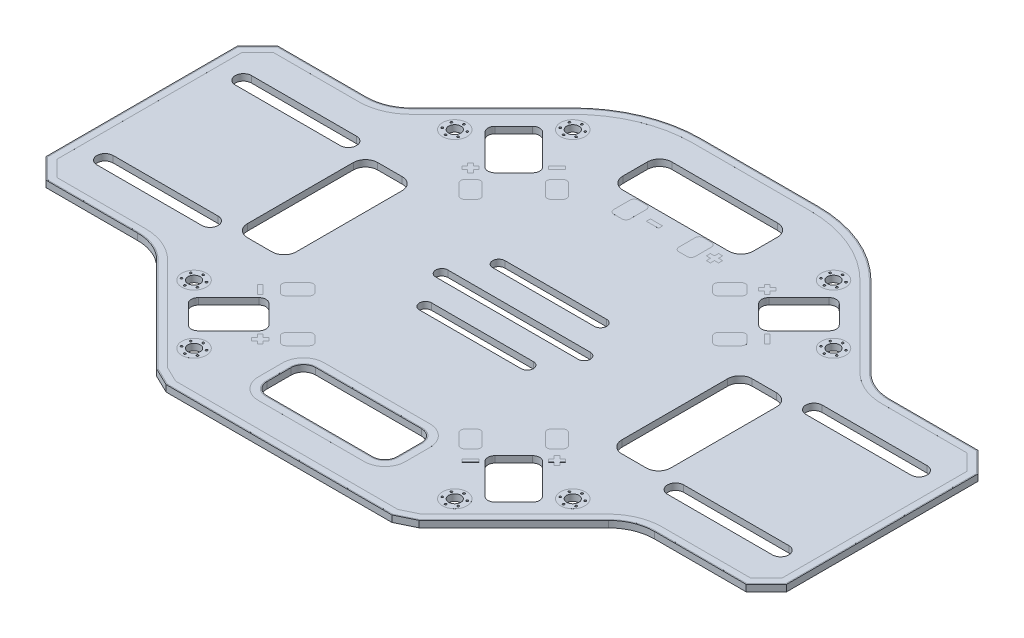
from build123d import *

# Parameters (mm, degrees)
SKETCH1_R                = 1.5
BOSS_EXTRUDE1_DEPTH      = 0.8
BOSS_EXTRUDE1_DEPTH_BACK = 0.8
SKETCH2_R                = 3
SKETCH2_R_2              = 0.25
SKETCH2_R_3              = 1.5
BOSS_EXTRUDE2_DEPTH      = 0.001
BOSS_EXTRUDE4_DEPTH      = 0.001
SKETCH6_R                = 0.25
CUT_EXTRUDE2_DEPTH       = 1.6
SKETCH7_W                = 3
SKETCH7_H                = 1
BOSS_EXTRUDE5_DEPTH      = 0.001


with BuildPart() as part:
    # Sketch1 → Boss-Extrude1 (new body, two sides)
    with BuildSketch(Plane(origin=(0, 0, 0), x_dir=(1, 0, 0), z_dir=(0, 1, 0))) as boss_extrude1_sk:
        with BuildLine():
            Line((-27.75, -57.681401017), (27.75, -57.681401017))
            Line((27.75, -57.681401017), (32.25, -55.501951545))
            Line((32.25, -55.501951545), (55.501951545, -32.25))
            ThreePointArc((55.501951545, -32.25), (59.171487368, -29.798094552), (63.5, -28.937099858))
            Line((63.5, -28.937099858), (86, -28.937099858))
            Line((86, -28.937099858), (91, -23.937099858))
            Line((91, -23.937099858), (91, 23.062900142))
            Line((91, 23.062900142), (86, 28.062900142))
            Line((86, 28.062900142), (64.302117422, 28.062900142))
            ThreePointArc((64.302117422, 28.062900142), (60.040200145, 28.910648198), (56.427121139, 31.324830407))
            Line((56.427121139, 31.324830407), (36.628131265, 51.12382028))
            ThreePointArc((36.628131265, 51.12382028), (26.443529141, 57.928953855), (14.429971817, 60.318598983))
            Line((14.429971817, 60.318598983), (-14.429971817, 60.318598983))
            ThreePointArc((-14.429971817, 60.318598983), (-26.443529141, 57.928953855), (-36.628131265, 51.12382028))
            Line((-36.628131265, 51.12382028), (-56.427121139, 31.324830407))
            ThreePointArc((-56.427121139, 31.324830407), (-60.040200145, 28.910648198), (-64.302117422, 28.062900142))
            Line((-64.302117422, 28.062900142), (-86, 28.062900142))
            Line((-86, 28.062900142), (-91, 23.062900142))
            Line((-91, 23.062900142), (-91, -23.937099858))
            Line((-91, -23.937099858), (-86, -28.937099858))
            Line((-86, -28.937099858), (-63.5, -28.937099858))
            ThreePointArc((-63.5, -28.937099858), (-59.171487368, -29.798094552), (-55.501951545, -32.25))
            Line((-55.501951545, -32.25), (-32.25, -55.501951545))
            Line((-32.25, -55.501951545), (-27.75, -57.681401017))
        make_face()
        with Locations((-32.031937188, 46.527626202)):
            Circle(SKETCH1_R, mode=Mode.SUBTRACT)
        with Locations((-46.527626202, 32.031937188)):
            Circle(SKETCH1_R, mode=Mode.SUBTRACT)
        with Locations((32.031937188, -46.527626202)):
            Circle(SKETCH1_R, mode=Mode.SUBTRACT)
        with Locations((46.527626202, -32.031937188)):
            Circle(SKETCH1_R, mode=Mode.SUBTRACT)
        with Locations((-46.527626202, -32.031937188)):
            Circle(SKETCH1_R, mode=Mode.SUBTRACT)
        with Locations((-32.031937188, -46.527626202)):
            Circle(SKETCH1_R, mode=Mode.SUBTRACT)
        with Locations((32.031937188, 46.527626202)):
            Circle(SKETCH1_R, mode=Mode.SUBTRACT)
        with Locations((46.527626202, 32.031937188)):
            Circle(SKETCH1_R, mode=Mode.SUBTRACT)
        with BuildLine():
            Line((-13, -47.681401017), (13, -47.681401017))
            ThreePointArc((13, -47.681401017), (15.121320344, -46.802721361), (16, -44.681401017))
            Line((16, -44.681401017), (16, -38.681401017))
            ThreePointArc((16, -38.681401017), (15.121320344, -36.560080673), (13, -35.681401017))
            Line((13, -35.681401017), (-13, -35.681401017))
            ThreePointArc((-13, -35.681401017), (-15.121320344, -36.560080673), (-16, -38.681401017))
            Line((-16, -38.681401017), (-16, -44.681401017))
            ThreePointArc((-16, -44.681401017), (-15.121320344, -46.802721361), (-13, -47.681401017))
        make_face(mode=Mode.SUBTRACT)
        with BuildLine():
            Line((37.688791437, -42.284985515), (42.284985515, -37.688791437))
            ThreePointArc((42.284985515, -37.688791437), (42.797548648, -36.45135457), (42.284985515, -35.213917703))
            Line((42.284985515, -35.213917703), (34.860364312, -27.789296501))
            ThreePointArc((34.860364312, -27.789296501), (33.622927445, -27.276733368), (32.385490578, -27.789296501))
            Line((32.385490578, -27.789296501), (27.789296501, -32.385490578))
            ThreePointArc((27.789296501, -32.385490578), (27.276733368, -33.622927445), (27.789296501, -34.860364312))
            Line((27.789296501, -34.860364312), (35.213917703, -42.284985515))
            ThreePointArc((35.213917703, -42.284985515), (36.45135457, -42.797548648), (37.688791437, -42.284985515))
        make_face(mode=Mode.SUBTRACT)
        with BuildLine():
            Line((-35.213917703, -42.284985515), (-27.789296501, -34.860364312))
            ThreePointArc((-27.789296501, -34.860364312), (-27.276733368, -33.622927445), (-27.789296501, -32.385490578))
            Line((-27.789296501, -32.385490578), (-32.385490578, -27.789296501))
            ThreePointArc((-32.385490578, -27.789296501), (-33.622927445, -27.276733368), (-34.860364312, -27.789296501))
            Line((-34.860364312, -27.789296501), (-42.284985515, -35.213917703))
            ThreePointArc((-42.284985515, -35.213917703), (-42.797548648, -36.45135457), (-42.284985515, -37.688791437))
            Line((-42.284985515, -37.688791437), (-37.688791437, -42.284985515))
            ThreePointArc((-37.688791437, -42.284985515), (-36.45135457, -42.797548648), (-35.213917703, -42.284985515))
        make_face(mode=Mode.SUBTRACT)
        with BuildLine():
            Line((-35.213917703, 42.284985515), (-27.789296501, 34.860364312))
            ThreePointArc((-27.789296501, 34.860364312), (-27.276733368, 33.622927445), (-27.789296501, 32.385490578))
            Line((-27.789296501, 32.385490578), (-32.385490578, 27.789296501))
            ThreePointArc((-32.385490578, 27.789296501), (-33.622927445, 27.276733368), (-34.860364312, 27.789296501))
            Line((-34.860364312, 27.789296501), (-42.284985515, 35.213917703))
            ThreePointArc((-42.284985515, 35.213917703), (-42.797548648, 36.45135457), (-42.284985515, 37.688791437))
            Line((-42.284985515, 37.688791437), (-37.688791437, 42.284985515))
            ThreePointArc((-37.688791437, 42.284985515), (-36.45135457, 42.797548648), (-35.213917703, 42.284985515))
        make_face(mode=Mode.SUBTRACT)
        with BuildLine():
            Line((37.688791437, 42.284985515), (42.284985515, 37.688791437))
            ThreePointArc((42.284985515, 37.688791437), (42.797548648, 36.45135457), (42.284985515, 35.213917703))
            Line((42.284985515, 35.213917703), (34.860364312, 27.789296501))
            ThreePointArc((34.860364312, 27.789296501), (33.622927445, 27.276733368), (32.385490578, 27.789296501))
            Line((32.385490578, 27.789296501), (27.789296501, 32.385490578))
            ThreePointArc((27.789296501, 32.385490578), (27.276733368, 33.622927445), (27.789296501, 34.860364312))
            Line((27.789296501, 34.860364312), (35.213917703, 42.284985515))
            ThreePointArc((35.213917703, 42.284985515), (36.45135457, 42.797548648), (37.688791437, 42.284985515))
        make_face(mode=Mode.SUBTRACT)
        with BuildLine():
            Line((-13, 51.818598983), (13, 51.818598983))
            ThreePointArc((13, 51.818598983), (15.121320344, 50.939919327), (16, 48.818598983))
            Line((16, 48.818598983), (16, 42.818598983))
            ThreePointArc((16, 42.818598983), (15.121320344, 40.697278639), (13, 39.818598983))
            Line((13, 39.818598983), (-13, 39.818598983))
            ThreePointArc((-13, 39.818598983), (-15.121320344, 40.697278639), (-16, 42.818598983))
            Line((-16, 42.818598983), (-16, 48.818598983))
            ThreePointArc((-16, 48.818598983), (-15.121320344, 50.939919327), (-13, 51.818598983))
        make_face(mode=Mode.SUBTRACT)
        with BuildLine():
            Line((-12.5, -10.681401017), (12.5, -10.681401017))
            ThreePointArc((12.5, -10.681401017), (14, -9.181401017), (12.5, -7.681401017))
            Line((12.5, -7.681401017), (-12.5, -7.681401017))
            ThreePointArc((-12.5, -7.681401017), (-14, -9.181401017), (-12.5, -10.681401017))
        make_face(mode=Mode.SUBTRACT)
        with BuildLine():
            Line((-17.5, -1.681401017), (17.5, -1.681401017))
            ThreePointArc((17.5, -1.681401017), (19, -0.181401017), (17.5, 1.318598983))
            Line((17.5, 1.318598983), (-17.5, 1.318598983))
            ThreePointArc((-17.5, 1.318598983), (-19, -0.181401017), (-17.5, -1.681401017))
        make_face(mode=Mode.SUBTRACT)
        with BuildLine():
            Line((-12.5, 7.318598983), (12.5, 7.318598983))
            ThreePointArc((12.5, 7.318598983), (14, 8.818598983), (12.5, 10.318598983))
            Line((12.5, 10.318598983), (-12.5, 10.318598983))
            ThreePointArc((-12.5, 10.318598983), (-14, 8.818598983), (-12.5, 7.318598983))
        make_face(mode=Mode.SUBTRACT)
        with BuildLine():
            Line((-52, 12.562900142), (-52, -13.437099858))
            ThreePointArc((-52, -13.437099858), (-51.121320344, -15.558420201), (-49, -16.437099858))
            Line((-49, -16.437099858), (-43, -16.437099858))
            ThreePointArc((-43, -16.437099858), (-40.878679656, -15.558420201), (-40, -13.437099858))
            Line((-40, -13.437099858), (-40, 12.562900142))
            ThreePointArc((-40, 12.562900142), (-40.878679656, 14.684220486), (-43, 15.562900142))
            Line((-43, 15.562900142), (-49, 15.562900142))
            ThreePointArc((-49, 15.562900142), (-51.121320344, 14.684220486), (-52, 12.562900142))
        make_face(mode=Mode.SUBTRACT)
        with BuildLine():
            Line((52, 12.562900142), (52, -13.437099858))
            ThreePointArc((52, -13.437099858), (51.121320344, -15.558420201), (49, -16.437099858))
            Line((49, -16.437099858), (43, -16.437099858))
            ThreePointArc((43, -16.437099858), (40.878679656, -15.558420201), (40, -13.437099858))
            Line((40, -13.437099858), (40, 12.562900142))
            ThreePointArc((40, 12.562900142), (40.878679656, 14.684220486), (43, 15.562900142))
            Line((43, 15.562900142), (49, 15.562900142))
            ThreePointArc((49, 15.562900142), (51.121320344, 14.684220486), (52, 12.562900142))
        make_face(mode=Mode.SUBTRACT)
        with BuildLine():
            Line((-83, 18.562900142), (-57.2, 18.562900142))
            ThreePointArc((-57.2, 18.562900142), (-55.2, 16.562900142), (-57.2, 14.562900142))
            Line((-57.2, 14.562900142), (-83, 14.562900142))
            ThreePointArc((-83, 14.562900142), (-85, 16.562900142), (-83, 18.562900142))
        make_face(mode=Mode.SUBTRACT)
        with BuildLine():
            Line((-83, -15.437099858), (-57.2, -15.437099858))
            ThreePointArc((-57.2, -15.437099858), (-55.2, -17.437099858), (-57.2, -19.437099858))
            Line((-57.2, -19.437099858), (-83, -19.437099858))
            ThreePointArc((-83, -19.437099858), (-85, -17.437099858), (-83, -15.437099858))
        make_face(mode=Mode.SUBTRACT)
        with BuildLine():
            Line((57.2, -15.437099858), (83, -15.437099858))
            ThreePointArc((83, -15.437099858), (85, -17.437099858), (83, -19.437099858))
            Line((83, -19.437099858), (57.2, -19.437099858))
            ThreePointArc((57.2, -19.437099858), (55.2, -17.437099858), (57.2, -15.437099858))
        make_face(mode=Mode.SUBTRACT)
        with BuildLine():
            Line((57.2, 18.562900142), (83, 18.562900142))
            ThreePointArc((83, 18.562900142), (85, 16.562900142), (83, 14.562900142))
            Line((83, 14.562900142), (57.2, 14.562900142))
            ThreePointArc((57.2, 14.562900142), (55.2, 16.562900142), (57.2, 18.562900142))
        make_face(mode=Mode.SUBTRACT)
    extrude(amount=BOSS_EXTRUDE1_DEPTH)
    extrude(boss_extrude1_sk.sketch, amount=-BOSS_EXTRUDE1_DEPTH_BACK)

    # Sketch2 → Boss-Extrude2 (add)
    with BuildSketch(Plane(origin=(0, 0.8, 0), x_dir=(1, 0, 0), z_dir=(0, 1, 0))):
        with BuildLine():
            ThreePointArc((56.250344443, 31.148053711), (59.944529287, 28.679678315), (64.302117422, 27.812900142))
            Line((64.302117422, 27.812900142), (85.896446609, 27.812900142))
            Line((85.896446609, 27.812900142), (90.75, 22.959346752))
            Line((90.75, 22.959346752), (90.75, -23.833546467))
            Line((90.75, -23.833546467), (85.896446609, -28.687099858))
            Line((85.896446609, -28.687099858), (63.5, -28.687099858))
            ThreePointArc((63.5, -28.687099858), (59.075816509, -29.567124669), (55.32517485, -32.073223305))
            Line((55.32517485, -32.073223305), (32.10305631, -55.295341845))
            Line((32.10305631, -55.295341845), (27.692646067, -57.431401017))
            Line((27.692646067, -57.431401017), (-27.692646067, -57.431401017))
            Line((-27.692646067, -57.431401017), (-32.10305631, -55.295341845))
            Line((-32.10305631, -55.295341845), (-55.32517485, -32.073223305))
            ThreePointArc((-55.32517485, -32.073223305), (-59.075816509, -29.567124669), (-63.5, -28.687099858))
            Line((-63.5, -28.687099858), (-85.896446609, -28.687099858))
            Line((-85.896446609, -28.687099858), (-90.75, -23.833546467))
            Line((-90.75, -23.833546467), (-90.75, 22.959346752))
            Line((-90.75, 22.959346752), (-85.896446609, 27.812900142))
            Line((-85.896446609, 27.812900142), (-64.302117422, 27.812900142))
            ThreePointArc((-64.302117422, 27.812900142), (-59.944529287, 28.679678315), (-56.250344443, 31.148053711))
            Line((-56.250344443, 31.148053711), (-36.45135457, 50.947043584))
            ThreePointArc((-36.45135457, 50.947043584), (-26.347858283, 57.697983972), (-14.429971817, 60.068598983))
            Line((-14.429971817, 60.068598983), (14.429971817, 60.068598983))
            ThreePointArc((14.429971817, 60.068598983), (26.347858283, 57.697983972), (36.45135457, 50.947043584))
            Line((36.45135457, 50.947043584), (56.250344443, 31.148053711))
        make_face()
        with BuildLine():
            Line((-85.212994231, 26.162900142), (-64.302117422, 26.162900142))
            ThreePointArc((-64.302117422, 26.162900142), (-59.313101623, 27.155277086), (-55.083618254, 29.981327522))
            Line((-55.083618254, 29.981327522), (-35.284628381, 49.780317396))
            ThreePointArc((-35.284628381, 49.780317396), (-25.71643062, 56.173582743), (-14.429971817, 58.418598983))
            Line((-14.429971817, 58.418598983), (14.429971817, 58.418598983))
            ThreePointArc((14.429971817, 58.418598983), (25.71643062, 56.173582743), (35.284628381, 49.780317396))
            Line((35.284628381, 49.780317396), (55.083618254, 29.981327522))
            ThreePointArc((55.083618254, 29.981327522), (59.313101623, 27.155277086), (64.302117422, 26.162900142))
            Line((64.302117422, 26.162900142), (85.212994231, 26.162900142))
            Line((85.212994231, 26.162900142), (89.1, 22.275894374))
            Line((89.1, 22.275894374), (89.1, -23.150094089))
            Line((89.1, -23.150094089), (85.212994231, -27.037099858))
            Line((85.212994231, -27.037099858), (63.5, -27.037099858))
            ThreePointArc((63.5, -27.037099858), (58.444388846, -28.042723441), (54.158448661, -30.906497116))
            Line((54.158448661, -30.906497116), (31.133227955, -53.931717821))
            Line((31.133227955, -53.931717821), (27.314110106, -55.781401017))
            Line((27.314110106, -55.781401017), (-27.314110106, -55.781401017))
            Line((-27.314110106, -55.781401017), (-31.133227955, -53.931717821))
            Line((-31.133227955, -53.931717821), (-54.158448661, -30.906497116))
            ThreePointArc((-54.158448661, -30.906497116), (-58.444388846, -28.042723441), (-63.5, -27.037099858))
            Line((-63.5, -27.037099858), (-85.212994231, -27.037099858))
            Line((-85.212994231, -27.037099858), (-89.1, -23.150094089))
            Line((-89.1, -23.150094089), (-89.1, 22.275894374))
            Line((-89.1, 22.275894374), (-85.212994231, 26.162900142))
        make_face(mode=Mode.SUBTRACT)
        with Locations((-32.031937188, -46.527626202)):
            Circle(SKETCH2_R)
        with Locations((-33.980494346, -45.402626202)):
            Circle(SKETCH2_R_2, mode=Mode.SUBTRACT)
        with Locations((-33.980494346, -47.652626202)):
            Circle(SKETCH2_R_2, mode=Mode.SUBTRACT)
        with Locations((-32.031937188, -48.777626202)):
            Circle(SKETCH2_R_2, mode=Mode.SUBTRACT)
        with Locations((-30.083380029, -47.652626202)):
            Circle(SKETCH2_R_2, mode=Mode.SUBTRACT)
        with Locations((-30.083380029, -45.402626202)):
            Circle(SKETCH2_R_2, mode=Mode.SUBTRACT)
        with Locations((-32.031937188, -44.277626202)):
            Circle(SKETCH2_R_2, mode=Mode.SUBTRACT)
        with Locations((-32.031937188, -46.527626202)):
            Circle(SKETCH2_R_3, mode=Mode.SUBTRACT)
        with Locations((-46.527626202, -32.031937188)):
            Circle(SKETCH2_R)
        with Locations((-48.476183361, -30.906937188)):
            Circle(SKETCH2_R_2, mode=Mode.SUBTRACT)
        with Locations((-48.476183361, -33.156937188)):
            Circle(SKETCH2_R_2, mode=Mode.SUBTRACT)
        with Locations((-46.527626202, -34.281937188)):
            Circle(SKETCH2_R_2, mode=Mode.SUBTRACT)
        with Locations((-44.579069044, -33.156937188)):
            Circle(SKETCH2_R_2, mode=Mode.SUBTRACT)
        with Locations((-44.579069044, -30.906937188)):
            Circle(SKETCH2_R_2, mode=Mode.SUBTRACT)
        with Locations((-46.527626202, -29.781937188)):
            Circle(SKETCH2_R_2, mode=Mode.SUBTRACT)
        with Locations((-46.527626202, -32.031937188)):
            Circle(SKETCH2_R_3, mode=Mode.SUBTRACT)
        with Locations((-46.527626202, 32.031937188)):
            Circle(SKETCH2_R)
        with Locations((-48.476183361, 30.906937188)):
            Circle(SKETCH2_R_2, mode=Mode.SUBTRACT)
        with Locations((-48.476183361, 33.156937188)):
            Circle(SKETCH2_R_2, mode=Mode.SUBTRACT)
        with Locations((-46.527626202, 34.281937188)):
            Circle(SKETCH2_R_2, mode=Mode.SUBTRACT)
        with Locations((-44.579069044, 33.156937188)):
            Circle(SKETCH2_R_2, mode=Mode.SUBTRACT)
        with Locations((-44.579069044, 30.906937188)):
            Circle(SKETCH2_R_2, mode=Mode.SUBTRACT)
        with Locations((-46.527626202, 29.781937188)):
            Circle(SKETCH2_R_2, mode=Mode.SUBTRACT)
        with Locations((-46.527626202, 32.031937188)):
            Circle(SKETCH2_R_3, mode=Mode.SUBTRACT)
        with Locations((-32.031937188, 46.527626202)):
            Circle(SKETCH2_R)
        with Locations((-33.980494346, 45.402626202)):
            Circle(SKETCH2_R_2, mode=Mode.SUBTRACT)
        with Locations((-33.980494346, 47.652626202)):
            Circle(SKETCH2_R_2, mode=Mode.SUBTRACT)
        with Locations((-32.031937188, 44.277626202)):
            Circle(SKETCH2_R_2, mode=Mode.SUBTRACT)
        with Locations((-30.083380029, 45.402626202)):
            Circle(SKETCH2_R_2, mode=Mode.SUBTRACT)
        with Locations((-30.083380029, 47.652626202)):
            Circle(SKETCH2_R_2, mode=Mode.SUBTRACT)
        with Locations((-32.031937188, 48.777626202)):
            Circle(SKETCH2_R_2, mode=Mode.SUBTRACT)
        with Locations((-32.031937188, 46.527626202)):
            Circle(SKETCH2_R_3, mode=Mode.SUBTRACT)
        with Locations((32.031937188, 46.527626202)):
            Circle(SKETCH2_R)
        with Locations((30.083380029, 45.402626202)):
            Circle(SKETCH2_R_2, mode=Mode.SUBTRACT)
        with Locations((30.083380029, 47.652626202)):
            Circle(SKETCH2_R_2, mode=Mode.SUBTRACT)
        with Locations((32.031937188, 48.777626202)):
            Circle(SKETCH2_R_2, mode=Mode.SUBTRACT)
        with Locations((33.980494346, 47.652626202)):
            Circle(SKETCH2_R_2, mode=Mode.SUBTRACT)
        with Locations((33.980494346, 45.402626202)):
            Circle(SKETCH2_R_2, mode=Mode.SUBTRACT)
        with Locations((32.031937188, 44.277626202)):
            Circle(SKETCH2_R_2, mode=Mode.SUBTRACT)
        with Locations((32.031937188, 46.527626202)):
            Circle(SKETCH2_R_3, mode=Mode.SUBTRACT)
        with Locations((46.527626202, 32.031937188)):
            Circle(SKETCH2_R)
        with Locations((44.579069044, 30.906937188)):
            Circle(SKETCH2_R_2, mode=Mode.SUBTRACT)
        with Locations((44.579069044, 33.156937188)):
            Circle(SKETCH2_R_2, mode=Mode.SUBTRACT)
        with Locations((46.527626202, 34.281937188)):
            Circle(SKETCH2_R_2, mode=Mode.SUBTRACT)
        with Locations((48.476183361, 33.156937188)):
            Circle(SKETCH2_R_2, mode=Mode.SUBTRACT)
        with Locations((48.476183361, 30.906937188)):
            Circle(SKETCH2_R_2, mode=Mode.SUBTRACT)
        with Locations((46.527626202, 29.781937188)):
            Circle(SKETCH2_R_2, mode=Mode.SUBTRACT)
        with Locations((46.527626202, 32.031937188)):
            Circle(SKETCH2_R_3, mode=Mode.SUBTRACT)
        with Locations((46.527626202, -32.031937188)):
            Circle(SKETCH2_R)
        with Locations((44.579069044, -33.156937188)):
            Circle(SKETCH2_R_2, mode=Mode.SUBTRACT)
        with Locations((44.579069044, -30.906937188)):
            Circle(SKETCH2_R_2, mode=Mode.SUBTRACT)
        with Locations((46.527626202, -29.781937188)):
            Circle(SKETCH2_R_2, mode=Mode.SUBTRACT)
        with Locations((48.476183361, -30.906937188)):
            Circle(SKETCH2_R_2, mode=Mode.SUBTRACT)
        with Locations((48.476183361, -33.156937188)):
            Circle(SKETCH2_R_2, mode=Mode.SUBTRACT)
        with Locations((46.527626202, -34.281937188)):
            Circle(SKETCH2_R_2, mode=Mode.SUBTRACT)
        with Locations((46.527626202, -32.031937188)):
            Circle(SKETCH2_R_3, mode=Mode.SUBTRACT)
        with Locations((32.031937188, -46.527626202)):
            Circle(SKETCH2_R)
        with Locations((30.083380029, -45.402626202)):
            Circle(SKETCH2_R_2, mode=Mode.SUBTRACT)
        with Locations((30.083380029, -47.652626202)):
            Circle(SKETCH2_R_2, mode=Mode.SUBTRACT)
        with Locations((32.031937188, -48.777626202)):
            Circle(SKETCH2_R_2, mode=Mode.SUBTRACT)
        with Locations((33.980494346, -47.652626202)):
            Circle(SKETCH2_R_2, mode=Mode.SUBTRACT)
        with Locations((33.980494346, -45.402626202)):
            Circle(SKETCH2_R_2, mode=Mode.SUBTRACT)
        with Locations((32.031937188, -44.277626202)):
            Circle(SKETCH2_R_2, mode=Mode.SUBTRACT)
        with Locations((32.031937188, -46.527626202)):
            Circle(SKETCH2_R_3, mode=Mode.SUBTRACT)
        with BuildLine():
            Line((-13, -33.631401017), (13, -33.631401017))
            ThreePointArc((13, -33.631401017), (16.570889245, -35.110511772), (18.05, -38.681401017))
            Line((18.05, -38.681401017), (18.05, -44.681401017))
            ThreePointArc((18.05, -44.681401017), (16.570889245, -48.252290262), (13, -49.731401017))
            Line((13, -49.731401017), (-13, -49.731401017))
            ThreePointArc((-13, -49.731401017), (-16.570889245, -48.252290262), (-18.05, -44.681401017))
            Line((-18.05, -44.681401017), (-18.05, -38.681401017))
            ThreePointArc((-18.05, -38.681401017), (-16.570889245, -35.110511772), (-13, -33.631401017))
        make_face()
        with BuildLine():
            ThreePointArc((13, -47.931401017), (15.298097039, -46.979498056), (16.25, -44.681401017))
            Line((16.25, -44.681401017), (16.25, -38.681401017))
            ThreePointArc((16.25, -38.681401017), (15.298097039, -36.383303978), (13, -35.431401017))
            Line((13, -35.431401017), (-13, -35.431401017))
            ThreePointArc((-13, -35.431401017), (-15.298097039, -36.383303978), (-16.25, -38.681401017))
            Line((-16.25, -38.681401017), (-16.25, -44.681401017))
            ThreePointArc((-16.25, -44.681401017), (-15.298097039, -46.979498056), (-13, -47.931401017))
            Line((-13, -47.931401017), (13, -47.931401017))
        make_face(mode=Mode.SUBTRACT)
    boss_extrude2 = extrude(amount=BOSS_EXTRUDE2_DEPTH)

    # Mirror1: Boss-Extrude2 across plane
    add(boss_extrude2.mirror(Plane.ZX))

    # Sketch5 → Boss-Extrude4 (add)
    with BuildSketch(Plane(origin=(0, 0.8, 0), x_dir=(1, 0, 0), z_dir=(0, 1, 0))):
        Polygon((35.744247789, -27.258966415), (36.45135457, -26.551859634), (37.158461351, -27.258966415), (37.865568133, -26.551859634), (37.158461351, -25.844752852), (37.865568133, -25.137646071), (37.158461351, -24.43053929), (36.45135457, -25.137646071), (35.744247789, -24.43053929), (35.037141008, -25.137646071), (35.744247789, -25.844752852), (35.037141008, -26.551859634), align=None)
        Polygon((26.551859634, -35.037141008), (27.258966415, -35.744247789), (25.137646071, -37.865568133), (24.43053929, -37.158461351), align=None)
        Polygon((-37.158461351, -24.43053929), (-37.865568133, -25.137646071), (-35.744247789, -27.258966415), (-35.037141008, -26.551859634), align=None)
        Polygon((-26.551859634, -35.037141008), (-27.258966415, -35.744247789), (-26.551859634, -36.45135457), (-27.258966415, -37.158461351), (-26.551859634, -37.865568133), (-25.844752852, -37.158461351), (-25.137646071, -37.865568133), (-24.43053929, -37.158461351), (-25.137646071, -36.45135457), (-24.43053929, -35.744247789), (-25.137646071, -35.037141008), (-25.844752852, -35.744247789), align=None)
        Polygon((-24.43053929, 37.158461351), (-25.137646071, 37.865568133), (-27.258966415, 35.744247789), (-26.551859634, 35.037141008), align=None)
        Polygon((-35.037141008, 26.551859634), (-35.744247789, 27.258966415), (-36.45135457, 26.551859634), (-37.158461351, 27.258966415), (-37.865568133, 26.551859634), (-37.158461351, 25.844752852), (-37.865568133, 25.137646071), (-37.158461351, 24.43053929), (-36.45135457, 25.137646071), (-35.744247789, 24.43053929), (-35.037141008, 25.137646071), (-35.744247789, 25.844752852), align=None)
        Polygon((37.158461351, 24.43053929), (37.865568133, 25.137646071), (35.744247789, 27.258966415), (35.037141008, 26.551859634), align=None)
        Polygon((26.551859634, 35.037141008), (27.258966415, 35.744247789), (26.551859634, 36.45135457), (27.258966415, 37.158461351), (26.551859634, 37.865568133), (25.844752852, 37.158461351), (25.137646071, 37.865568133), (24.43053929, 37.158461351), (25.137646071, 36.45135457), (24.43053929, 35.744247789), (25.137646071, 35.037141008), (25.844752852, 35.744247789), align=None)
        with BuildLine():
            Line((29.026733368, -19.834345212), (30.44094693, -18.42013165))
            ThreePointArc((30.44094693, -18.42013165), (31.148053711, -18.127238431), (31.855160492, -18.42013165))
            Line((31.855160492, -18.42013165), (34.683587617, -21.248558775))
            ThreePointArc((34.683587617, -21.248558775), (34.976480836, -21.955665556), (34.683587617, -22.662772337))
            Line((34.683587617, -22.662772337), (33.269374055, -24.076985899))
            ThreePointArc((33.269374055, -24.076985899), (32.562267274, -24.369879118), (31.855160492, -24.076985899))
            Line((31.855160492, -24.076985899), (29.026733368, -21.248558775))
            ThreePointArc((29.026733368, -21.248558775), (28.733840149, -20.541451993), (29.026733368, -19.834345212))
        make_face()
        with BuildLine():
            Line((18.42013165, -31.855160492), (21.248558775, -34.683587617))
            ThreePointArc((21.248558775, -34.683587617), (21.955665556, -34.976480836), (22.662772337, -34.683587617))
            Line((22.662772337, -34.683587617), (24.076985899, -33.269374055))
            ThreePointArc((24.076985899, -33.269374055), (24.369879118, -32.562267274), (24.076985899, -31.855160492))
            Line((24.076985899, -31.855160492), (21.248558775, -29.026733368))
            ThreePointArc((21.248558775, -29.026733368), (20.541451993, -28.733840149), (19.834345212, -29.026733368))
            Line((19.834345212, -29.026733368), (18.42013165, -30.44094693))
            ThreePointArc((18.42013165, -30.44094693), (18.127238431, -31.148053711), (18.42013165, -31.855160492))
        make_face()
        with BuildLine():
            Line((-34.683587617, -22.662772337), (-33.269374055, -24.076985899))
            ThreePointArc((-33.269374055, -24.076985899), (-32.562267274, -24.369879118), (-31.855160492, -24.076985899))
            Line((-31.855160492, -24.076985899), (-29.026733368, -21.248558775))
            ThreePointArc((-29.026733368, -21.248558775), (-28.733840149, -20.541451993), (-29.026733368, -19.834345212))
            Line((-29.026733368, -19.834345212), (-30.44094693, -18.42013165))
            ThreePointArc((-30.44094693, -18.42013165), (-31.148053711, -18.127238431), (-31.855160492, -18.42013165))
            Line((-31.855160492, -18.42013165), (-34.683587617, -21.248558775))
            ThreePointArc((-34.683587617, -21.248558775), (-34.976480836, -21.955665556), (-34.683587617, -22.662772337))
        make_face()
        with BuildLine():
            Line((-21.248558775, -29.026733368), (-24.076985899, -31.855160492))
            ThreePointArc((-24.076985899, -31.855160492), (-24.369879118, -32.562267274), (-24.076985899, -33.269374055))
            Line((-24.076985899, -33.269374055), (-22.662772337, -34.683587617))
            ThreePointArc((-22.662772337, -34.683587617), (-21.955665556, -34.976480836), (-21.248558775, -34.683587617))
            Line((-21.248558775, -34.683587617), (-18.42013165, -31.855160492))
            ThreePointArc((-18.42013165, -31.855160492), (-18.127238431, -31.148053711), (-18.42013165, -30.44094693))
            Line((-18.42013165, -30.44094693), (-19.834345212, -29.026733368))
            ThreePointArc((-19.834345212, -29.026733368), (-20.541451993, -28.733840149), (-21.248558775, -29.026733368))
        make_face()
        with BuildLine():
            Line((-22.662772337, 34.683587617), (-24.076985899, 33.269374055))
            ThreePointArc((-24.076985899, 33.269374055), (-24.369879118, 32.562267274), (-24.076985899, 31.855160492))
            Line((-24.076985899, 31.855160492), (-21.248558775, 29.026733368))
            ThreePointArc((-21.248558775, 29.026733368), (-20.541451993, 28.733840149), (-19.834345212, 29.026733368))
            Line((-19.834345212, 29.026733368), (-18.42013165, 30.44094693))
            ThreePointArc((-18.42013165, 30.44094693), (-18.127238431, 31.148053711), (-18.42013165, 31.855160492))
            Line((-18.42013165, 31.855160492), (-21.248558775, 34.683587617))
            ThreePointArc((-21.248558775, 34.683587617), (-21.955665556, 34.976480836), (-22.662772337, 34.683587617))
        make_face()
        with BuildLine():
            Line((-29.026733368, 21.248558775), (-31.855160492, 24.076985899))
            ThreePointArc((-31.855160492, 24.076985899), (-32.562267274, 24.369879118), (-33.269374055, 24.076985899))
            Line((-33.269374055, 24.076985899), (-34.683587617, 22.662772337))
            ThreePointArc((-34.683587617, 22.662772337), (-34.976480836, 21.955665556), (-34.683587617, 21.248558775))
            Line((-34.683587617, 21.248558775), (-31.855160492, 18.42013165))
            ThreePointArc((-31.855160492, 18.42013165), (-31.148053711, 18.127238431), (-30.44094693, 18.42013165))
            Line((-30.44094693, 18.42013165), (-29.026733368, 19.834345212))
            ThreePointArc((-29.026733368, 19.834345212), (-28.733840149, 20.541451993), (-29.026733368, 21.248558775))
        make_face()
        with BuildLine():
            Line((34.683587617, 22.662772337), (33.269374055, 24.076985899))
            ThreePointArc((33.269374055, 24.076985899), (32.562267274, 24.369879118), (31.855160492, 24.076985899))
            Line((31.855160492, 24.076985899), (29.026733368, 21.248558775))
            ThreePointArc((29.026733368, 21.248558775), (28.733840149, 20.541451993), (29.026733368, 19.834345212))
            Line((29.026733368, 19.834345212), (30.44094693, 18.42013165))
            ThreePointArc((30.44094693, 18.42013165), (31.148053711, 18.127238431), (31.855160492, 18.42013165))
            Line((31.855160492, 18.42013165), (34.683587617, 21.248558775))
            ThreePointArc((34.683587617, 21.248558775), (34.976480836, 21.955665556), (34.683587617, 22.662772337))
        make_face()
        with BuildLine():
            Line((21.248558775, 29.026733368), (24.076985899, 31.855160492))
            ThreePointArc((24.076985899, 31.855160492), (24.369879118, 32.562267274), (24.076985899, 33.269374055))
            Line((24.076985899, 33.269374055), (22.662772337, 34.683587617))
            ThreePointArc((22.662772337, 34.683587617), (21.955665556, 34.976480836), (21.248558775, 34.683587617))
            Line((21.248558775, 34.683587617), (18.42013165, 31.855160492))
            ThreePointArc((18.42013165, 31.855160492), (18.127238431, 31.148053711), (18.42013165, 30.44094693))
            Line((18.42013165, 30.44094693), (19.834345212, 29.026733368))
            ThreePointArc((19.834345212, 29.026733368), (20.541451993, 28.733840149), (21.248558775, 29.026733368))
        make_face()
    extrude(amount=BOSS_EXTRUDE4_DEPTH)

    # Sketch6 → Cut-Extrude2 (cut)
    with BuildSketch(Plane(origin=(0, 0.8, 0), x_dir=(1, 0, 0), z_dir=(0, 1, 0))):
        with Locations((-48.476183361, 33.156937188)):
            Circle(SKETCH6_R)
        with Locations((-46.527626202, 34.281937188)):
            Circle(SKETCH6_R)
        with Locations((-44.579069044, 33.156937188)):
            Circle(SKETCH6_R)
        with Locations((-48.476183361, 30.906937188)):
            Circle(SKETCH6_R)
        with Locations((-46.527626202, 29.781937188)):
            Circle(SKETCH6_R)
        with Locations((-44.579069044, 30.906937188)):
            Circle(SKETCH6_R)
        with Locations((-33.980494346, 45.402626202)):
            Circle(SKETCH6_R)
        with Locations((-32.031937188, 48.777626202)):
            Circle(SKETCH6_R)
        with Locations((-33.980494346, 47.652626202)):
            Circle(SKETCH6_R)
        with Locations((-32.031937188, 44.277626202)):
            Circle(SKETCH6_R)
        with Locations((-30.083380029, 47.652626202)):
            Circle(SKETCH6_R)
        with Locations((-30.083380029, 45.402626202)):
            Circle(SKETCH6_R)
        with Locations((30.083380029, 47.652626202)):
            Circle(SKETCH6_R)
        with Locations((32.031937188, 48.777626202)):
            Circle(SKETCH6_R)
        with Locations((33.980494346, 47.652626202)):
            Circle(SKETCH6_R)
        with Locations((33.980494346, 45.402626202)):
            Circle(SKETCH6_R)
        with Locations((30.083380029, 45.402626202)):
            Circle(SKETCH6_R)
        with Locations((32.031937188, 44.277626202)):
            Circle(SKETCH6_R)
        with Locations((46.527626202, 34.281937188)):
            Circle(SKETCH6_R)
        with Locations((48.476183361, 30.906937188)):
            Circle(SKETCH6_R)
        with Locations((44.579069044, 33.156937188)):
            Circle(SKETCH6_R)
        with Locations((48.476183361, 33.156937188)):
            Circle(SKETCH6_R)
        with Locations((46.527626202, 29.781937188)):
            Circle(SKETCH6_R)
        with Locations((44.579069044, 30.906937188)):
            Circle(SKETCH6_R)
        with Locations((44.579069044, -30.906937188)):
            Circle(SKETCH6_R)
        with Locations((46.527626202, -29.781937188)):
            Circle(SKETCH6_R)
        with Locations((44.579069044, -33.156937188)):
            Circle(SKETCH6_R)
        with Locations((48.476183361, -33.156937188)):
            Circle(SKETCH6_R)
        with Locations((48.476183361, -30.906937188)):
            Circle(SKETCH6_R)
        with Locations((46.527626202, -34.281937188)):
            Circle(SKETCH6_R)
        with Locations((32.031937188, -44.277626202)):
            Circle(SKETCH6_R)
        with Locations((30.083380029, -45.402626202)):
            Circle(SKETCH6_R)
        with Locations((30.083380029, -47.652626202)):
            Circle(SKETCH6_R)
        with Locations((33.980494346, -47.652626202)):
            Circle(SKETCH6_R)
        with Locations((32.031937188, -48.777626202)):
            Circle(SKETCH6_R)
        with Locations((33.980494346, -45.402626202)):
            Circle(SKETCH6_R)
        with Locations((-48.476183361, -30.906937188)):
            Circle(SKETCH6_R)
        with Locations((-44.579069044, -30.906937188)):
            Circle(SKETCH6_R)
        with Locations((-48.476183361, -33.156937188)):
            Circle(SKETCH6_R)
        with Locations((-46.527626202, -34.281937188)):
            Circle(SKETCH6_R)
        with Locations((-44.579069044, -33.156937188)):
            Circle(SKETCH6_R)
        with Locations((-46.527626202, -29.781937188)):
            Circle(SKETCH6_R)
        with Locations((-33.980494346, -45.402626202)):
            Circle(SKETCH6_R)
        with Locations((-32.031937188, -44.277626202)):
            Circle(SKETCH6_R)
        with Locations((-30.083380029, -45.402626202)):
            Circle(SKETCH6_R)
        with Locations((-30.083380029, -47.652626202)):
            Circle(SKETCH6_R)
        with Locations((-33.980494346, -47.652626202)):
            Circle(SKETCH6_R)
        with Locations((-32.031937188, -48.777626202)):
            Circle(SKETCH6_R)
    extrude(amount=-CUT_EXTRUDE2_DEPTH, mode=Mode.SUBTRACT)

    # Sketch7 → Boss-Extrude5 (add)
    with BuildSketch(Plane(origin=(0, 0.8, 0), x_dir=(1, 0, 0), z_dir=(0, 1, 0))):
        with BuildLine():
            Line((9, 39.568598983), (7, 39.568598983))
            ThreePointArc((7, 39.568598983), (6.292893219, 39.275705764), (6, 38.568598983))
            Line((6, 38.568598983), (6, 34.568598983))
            ThreePointArc((6, 34.568598983), (6.292893219, 33.861492202), (7, 33.568598983))
            Line((7, 33.568598983), (9, 33.568598983))
            ThreePointArc((9, 33.568598983), (9.707106781, 33.861492202), (10, 34.568598983))
            Line((10, 34.568598983), (10, 38.568598983))
            ThreePointArc((10, 38.568598983), (9.707106781, 39.275705764), (9, 39.568598983))
        make_face()
        with BuildLine():
            Line((-7, 39.568598983), (-9, 39.568598983))
            ThreePointArc((-9, 39.568598983), (-9.707106781, 39.275705764), (-10, 38.568598983))
            Line((-10, 38.568598983), (-10, 34.568598983))
            ThreePointArc((-10, 34.568598983), (-9.707106781, 33.861492202), (-9, 33.568598983))
            Line((-9, 33.568598983), (-7, 33.568598983))
            ThreePointArc((-7, 33.568598983), (-6.292893219, 33.861492202), (-6, 34.568598983))
            Line((-6, 34.568598983), (-6, 38.568598983))
            ThreePointArc((-6, 38.568598983), (-6.292893219, 39.275705764), (-7, 39.568598983))
        make_face()
        with Locations((-2, 36.568598983)):
            Rectangle(SKETCH7_W, SKETCH7_H)
        Polygon((14.25, 36.068598983), (13.25, 36.068598983), (13.25, 35.068598983), (12.25, 35.068598983), (12.25, 36.068598983), (11.25, 36.068598983), (11.25, 37.068598983), (12.25, 37.068598983), (12.25, 38.068598983), (13.25, 38.068598983), (13.25, 37.068598983), (14.25, 37.068598983), align=None)
    extrude(amount=BOSS_EXTRUDE5_DEPTH)


solid = part.part
